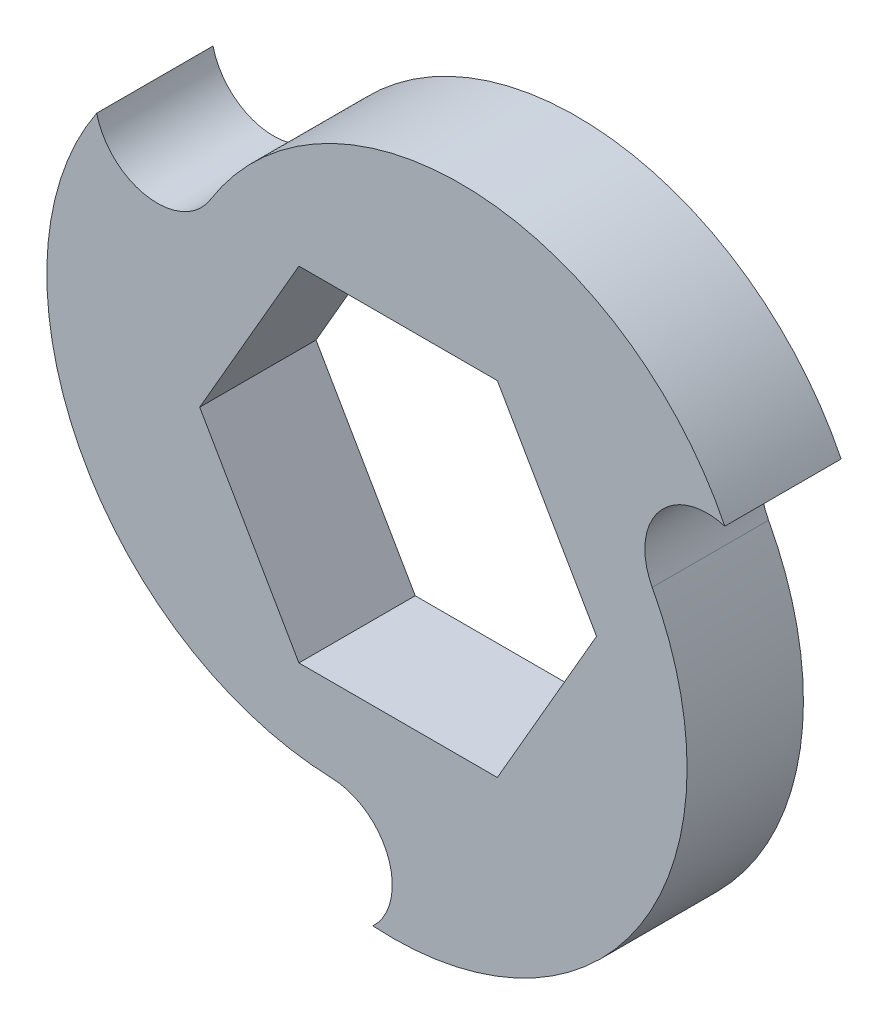
from build123d import *

# Parameters (mm, degrees)
BOSS_EXTRUDE1_DEPTH = 4.4


with BuildPart() as part:
    # Sketch1 → Boss-Extrude1 (new body)
    with BuildSketch(Plane.XY):
        with BuildLine():
            ThreePointArc((-7.106112246, 6.995417074), (2.908276026, 12.245932527), (12.355783111, 6.033002876))
            ThreePointArc((12.355783111, 6.033002876), (9.860301204, 5.257635244), (9.611265019, 2.65636519))
            ThreePointArc((9.611265019, 2.65636519), (9.151150649, -8.641607183), (-0.953157804, -13.716923496))
            ThreePointArc((-0.953157804, -13.716923496), (-0.376904917, -11.168088953), (-2.505152773, -9.651782264))
            ThreePointArc((-2.505152773, -9.651782264), (-12.059426674, -3.604325344), (-11.402625308, 7.68392062))
            ThreePointArc((-11.402625308, 7.68392062), (-9.483396287, 5.910453709), (-7.106112246, 6.995417074))
        make_face()
        Polygon((7.505553499, 0), (3.75277675, 6.5), (-3.75277675, 6.5), (-7.505553499, 0), (-3.75277675, -6.5), (3.75277675, -6.5), align=None, mode=Mode.SUBTRACT)
    extrude(amount=BOSS_EXTRUDE1_DEPTH)


solid = part.part
